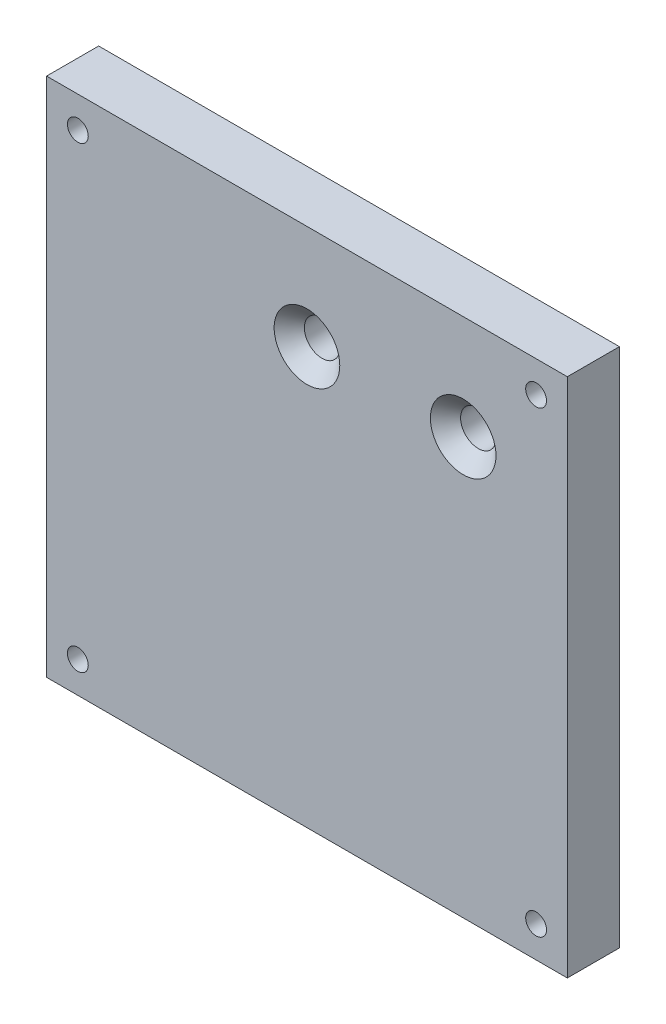
from build123d import *

# Parameters (mm, degrees)
ESQUISSE1_W                                       = 50
ESQUISSE1_H                                       = 50
ESQUISSE1_R                                       = 1
BOSS_EXTRU_1_DEPTH                                = 5
FRAISAGE_POUR_VIS_T_TE_FRAIS_E_M31_D              = 3.4
FRAISAGE_POUR_VIS_T_TE_FRAIS_E_M31_CSINK_D        = 6.3
FRAISAGE_POUR_VIS_T_TE_FRAIS_E_M31_CSINK_ANGLE    = 90
FRAISAGE_POUR_VIS_T_TE_FRAIS_E_M31_ON_D           = 3.4
FRAISAGE_POUR_VIS_T_TE_FRAIS_E_M31_ON_CSINK_D     = 6.3
FRAISAGE_POUR_VIS_T_TE_FRAIS_E_M31_ON_CSINK_ANGLE = 90


with BuildPart() as part:
    # Esquisse1 → Boss.-Extru.1 (new body)
    with BuildSketch(Plane.XY):
        with Locations((-13.443105546, 23.082518784)):
            Rectangle(ESQUISSE1_W, ESQUISSE1_H)
        with Locations((-35.443105546, 45.082518784)):
            Circle(ESQUISSE1_R, mode=Mode.SUBTRACT)
        with Locations((8.556894454, 45.082518784)):
            Circle(ESQUISSE1_R, mode=Mode.SUBTRACT)
        with Locations((8.556894454, 1.082518784)):
            Circle(ESQUISSE1_R, mode=Mode.SUBTRACT)
        with Locations((-35.443105546, 1.082518784)):
            Circle(ESQUISSE1_R, mode=Mode.SUBTRACT)
    extrude(amount=BOSS_EXTRU_1_DEPTH)

    # Fraisage pour vis à tête fraisée M31 (through all)
    with Locations(Plane(origin=(-13.443105546, 38.082518784, 5), x_dir=(1, 0, 0), z_dir=(0, 0, 1))):
        with Locations((0, 0), (15, 0)):
            CounterSinkHole(FRAISAGE_POUR_VIS_T_TE_FRAIS_E_M31_D / 2, FRAISAGE_POUR_VIS_T_TE_FRAIS_E_M31_CSINK_D / 2, counter_sink_angle=FRAISAGE_POUR_VIS_T_TE_FRAIS_E_M31_CSINK_ANGLE)

    # Fraisage pour vis à tête fraisée M31 on (through all)
    with Locations(Plane(origin=(-69.932791176, 61.393115675, 0), x_dir=(1, 0, 0), z_dir=(0, 0, 1))):
        with Locations((0, 0)):
            CounterSinkHole(FRAISAGE_POUR_VIS_T_TE_FRAIS_E_M31_ON_D / 2, FRAISAGE_POUR_VIS_T_TE_FRAIS_E_M31_ON_CSINK_D / 2, counter_sink_angle=FRAISAGE_POUR_VIS_T_TE_FRAIS_E_M31_ON_CSINK_ANGLE)


solid = part.part
